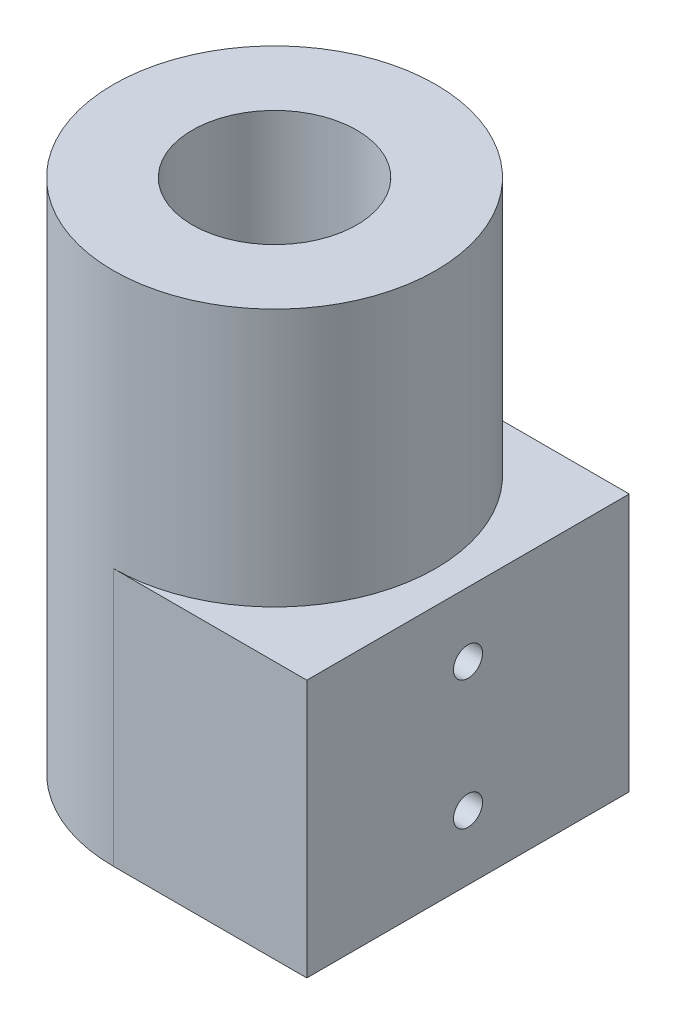
from build123d import *

# Parameters (mm, degrees)
SKETCH1_R                       = 25
BOSS_EXTRUDE1_DEPTH             = 80
SKETCH2_R                       = 12.75
CUT_EXTRUDE1_DEPTH              = 88.464278423
SKETCH3_R                       = 1.4
CUT_EXTRUDE2_DEPTH              = 88.464278423
BOSS_EXTRUDE2_REACH             = 99.596
BOSS_EXTRUDE2_END_RADIUS        = 25
SKETCH5_W                       = 50
SKETCH5_H                       = 40
BOSS_EXTRUDE2_DIRECTION_2_DEPTH = 5
SKETCH6_R                       = 2.25
CUT_EXTRUDE3_DEPTH              = 10


with BuildPart() as part:
    # Sketch1 → Boss-Extrude1 (new body)
    with BuildSketch(Plane(origin=(0, 0, 0), x_dir=(1, 0, 0), z_dir=(0, 1, 0))):
        Circle(SKETCH1_R)
    extrude(amount=BOSS_EXTRUDE1_DEPTH)

    # Sketch2 → Cut-Extrude1 (cut, through all)
    with BuildSketch(Plane(origin=(0, 80, 0), x_dir=(1, 0, 0), z_dir=(0, 1, 0))):
        Circle(SKETCH2_R)
    extrude(amount=-CUT_EXTRUDE1_DEPTH, mode=Mode.SUBTRACT)

    # Sketch3 → Cut-Extrude2 (cut, through all)
    with BuildSketch(Plane(origin=(0, 0, 0), x_dir=(0, 0, -1), z_dir=(1, 0, 0))):
        with Locations((0, 30)):
            Circle(SKETCH3_R)
        with Locations((0, 10)):
            Circle(SKETCH3_R)
    extrude(amount=-CUT_EXTRUDE2_DEPTH, mode=Mode.SUBTRACT)

    # Boss-Extrude2: up to this cylinder (the profile starts outside it)
    boss_extrude2_end = Plane(origin=(0, 20, 0), z_dir=(0, -1, 0)) * Cylinder(BOSS_EXTRUDE2_END_RADIUS, 250.192, mode=Mode.PRIVATE)
    # Sketch5 → Boss-Extrude2 (add, up to the surface)
    with BuildSketch(Plane(origin=(25, 0, 0), x_dir=(0, 0, -1), z_dir=(1, 0, 0)), mode=Mode.PRIVATE) as boss_extrude2_sk1:
        with Locations((0, 20)):
            Rectangle(SKETCH5_W, SKETCH5_H)
    boss_extrude2_tool1 = extrude(boss_extrude2_sk1.sketch, amount=-BOSS_EXTRUDE2_REACH, mode=Mode.PRIVATE) - boss_extrude2_end
    add(boss_extrude2_tool1.solids().sort_by_distance((25, 20, 0))[0])
    add(boss_extrude2_tool1.solids().sort_by_distance((25, 20, 0))[1])

    # Sketch5 → Boss-Extrude2 direction 2 (add)
    with BuildSketch(Plane(origin=(25, 0, 0), x_dir=(0, 0, -1), z_dir=(1, 0, 0))):
        with Locations((0, 20)):
            Rectangle(SKETCH5_W, SKETCH5_H)
    extrude(amount=BOSS_EXTRUDE2_DIRECTION_2_DEPTH)

    # Sketch6 → Cut-Extrude3 (cut)
    with BuildSketch(Plane(origin=(30, 0, 0), x_dir=(0, 0, -1), z_dir=(1, 0, 0))):
        with Locations((0, 10)):
            Circle(SKETCH6_R)
        with Locations((0, 30)):
            Circle(SKETCH6_R)
    extrude(amount=-CUT_EXTRUDE3_DEPTH, mode=Mode.SUBTRACT)


solid = part.part
